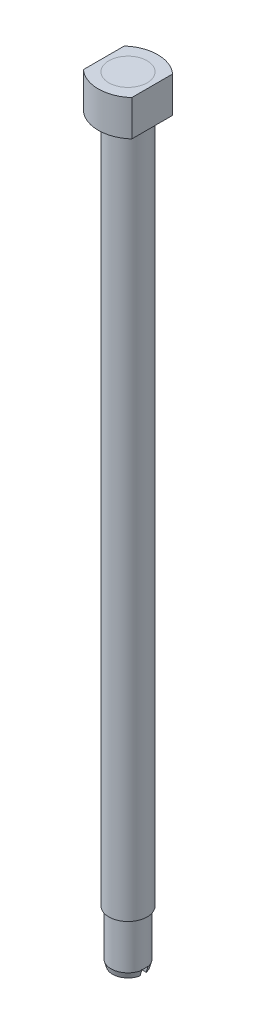
from build123d import *

# Parameters (mm, degrees)
SKETCH1_R           = 3.175
BOSS_EXTRUDE1_DEPTH = 119.761
SKETCH2_R           = 2.822872997
BOSS_EXTRUDE5_DEPTH = 7.62
CUT_EXTRUDE1_DEPTH  = 1.016
SKETCH12_R          = 3.175
BOSS_EXTRUDE6_DEPTH = 5.9436


with BuildPart() as part:
    # Sketch1 → Boss-Extrude1 (new body)
    with BuildSketch(Plane(origin=(0, 0, 0), x_dir=(1, 0, 0), z_dir=(0, 1, 0))):
        Circle(SKETCH1_R)
    extrude(amount=BOSS_EXTRUDE1_DEPTH)

    # Sketch2 → Boss-Extrude5 (add)
    with BuildSketch(Plane.XZ):
        Circle(SKETCH2_R)
    extrude(amount=BOSS_EXTRUDE5_DEPTH)

    # Sketch10 → Revolve1 (revolve)
    with BuildSketch(Plane(origin=(0, 0, 0), x_dir=(0, 0, -1), z_dir=(1, 0, 0))):
        Polygon((2.822872997, -7.62), (2.560464759, -8.542545863), (0, -8.542545863), (0, -7.62), align=None)
    revolve(axis=Axis((0, 0, 0), (0, -1, 0)))

    # Sketch11 → Cut-Extrude1 (cut)
    with BuildSketch(Plane.XZ.offset(8.542545863)):
        with BuildLine():
            Line((2.509564859, 0.508), (0, 0.508))
            Line((0, 0.508), (0, -0.508))
            Line((0, -0.508), (2.509564859, -0.508))
            ThreePointArc((2.509564859, -0.508), (2.547708005, -0.255271816), (2.560464759, 0))
            ThreePointArc((2.560464759, 0), (2.547708005, 0.255271816), (2.509564859, 0.508))
        make_face()
        with BuildLine():
            Line((0, -0.508), (0, 0.508))
            Line((0, 0.508), (-2.509564859, 0.508))
            ThreePointArc((-2.509564859, 0.508), (-2.560464759, 0), (-2.509564859, -0.508))
            Line((-2.509564859, -0.508), (0, -0.508))
        make_face()
        with BuildLine():
            ThreePointArc((-2.509564859, -0.508), (-2.560464759, 0), (-2.509564859, 0.508))
            Line((-2.509564859, 0.508), (-2.854276167, 0.508))
            Line((-2.854276167, 0.508), (-2.854276167, -0.508))
            Line((-2.854276167, -0.508), (-2.509564859, -0.508))
        make_face()
        with BuildLine():
            Line((2.854276167, 0.508), (2.509564859, 0.508))
            ThreePointArc((2.509564859, 0.508), (2.547708005, 0.255271816), (2.560464759, 0))
            ThreePointArc((2.560464759, 0), (2.547708005, -0.255271816), (2.509564859, -0.508))
            Line((2.509564859, -0.508), (2.854276167, -0.508))
            Line((2.854276167, -0.508), (2.854276167, 0.508))
        make_face()
    extrude(amount=-CUT_EXTRUDE1_DEPTH, mode=Mode.SUBTRACT)


with BuildPart() as body_2:
    # Sketch12 → Boss-Extrude6 (new body)
    with BuildSketch(Plane(origin=(0, 119.761, 0), x_dir=(1, 0, 0), z_dir=(0, 1, 0))):
        with BuildLine():
            Line((-4.0132, -3.3909), (-4.0132, 3.3909))
            ThreePointArc((-4.0132, 3.3909), (0, 4.9276), (4.0132, 3.3909))
            Line((4.0132, 3.3909), (4.0132, -3.3909))
            ThreePointArc((4.0132, -3.3909), (0, -4.9276), (-4.0132, -3.3909))
        make_face()
        Circle(SKETCH12_R, mode=Mode.SUBTRACT)
    extrude(amount=-BOSS_EXTRUDE6_DEPTH)


solid = Compound([part.part, body_2.part])
